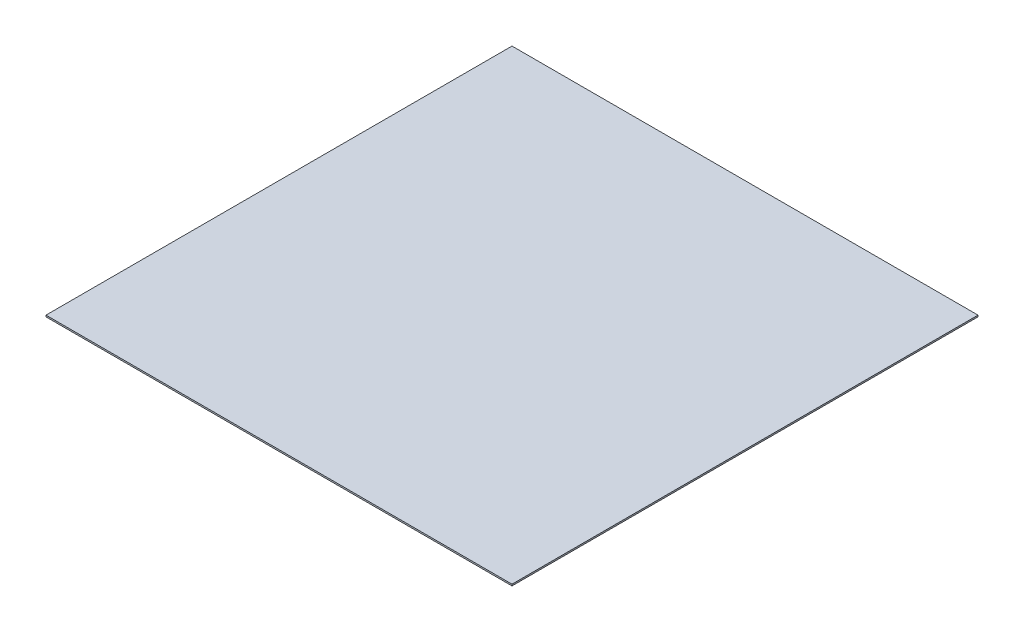
from build123d import *

# Parameters (mm, degrees)
SKETCH_1_W      = 300
SKETCH_1_H      = 300
EXTRUDE_1_DEPTH = 1


with BuildPart() as part:
    # 草图1 → 凸台-拉伸1 (new body)
    with BuildSketch(Plane(origin=(0, 0, 0), x_dir=(1, 0, 0), z_dir=(0, 1, 0))):
        with Locations((150, 150)):
            Rectangle(SKETCH_1_W, SKETCH_1_H)
    extrude(amount=EXTRUDE_1_DEPTH)


solid = part.part
